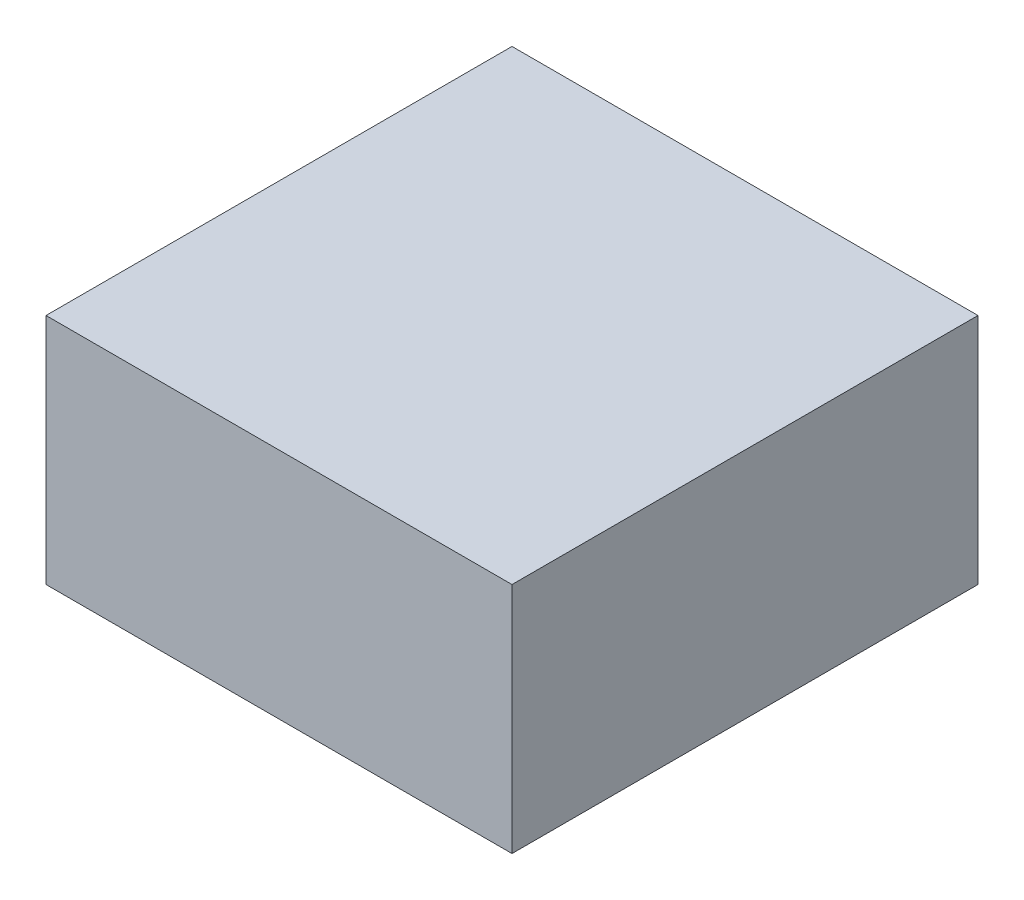
from build123d import *

# Parameters (mm, degrees)
SKETCH_1_W      = 50
SKETCH_1_H      = 50
EXTRUDE_1_DEPTH = 25


with BuildPart() as part:
    # 草图1 → 凸台-拉伸1 (new body)
    with BuildSketch(Plane(origin=(0, 0, 0), x_dir=(1, 0, 0), z_dir=(0, 1, 0))):
        Rectangle(SKETCH_1_W, SKETCH_1_H)
    extrude(amount=EXTRUDE_1_DEPTH)


solid = part.part
